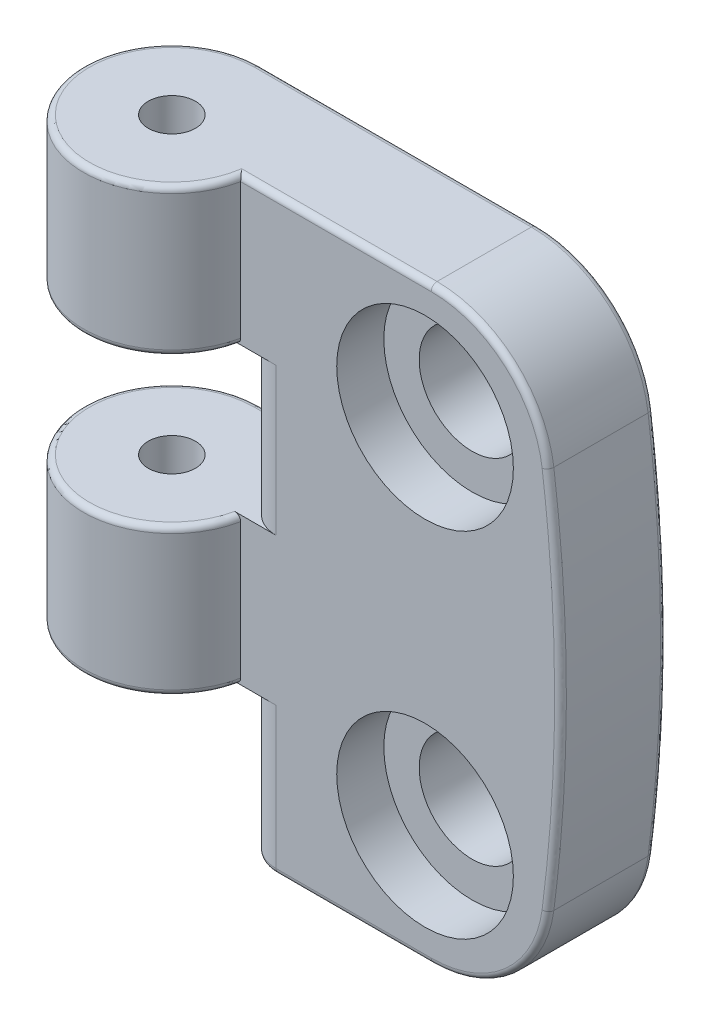
from build123d import *

# Parameters (mm, degrees)
SKETCH1_W                                           = 42
SKETCH1_H                                           = 50
BOSS_EXTRUDE1_DEPTH                                 = 15
SKETCH2_OUTSIDE_W                                   = 57.4
SKETCH2_OUTSIDE_H                                   = 30.4
SKETCH2_OUTSIDE_R                                   = 2
CUT_EXTRUDE1_DEPTH                                  = 51
CUT_EXTRUDE2_DEPTH                                  = 15
FILLET1_R                                           = 10
CBORE_FOR_M8_HEX_SOCKET_HEAD_CAP_SCREW1_D           = 9
CBORE_FOR_M8_HEX_SOCKET_HEAD_CAP_SCREW1_DEPTH       = 15
CBORE_FOR_M8_HEX_SOCKET_HEAD_CAP_SCREW1_CBORE_D     = 15
CBORE_FOR_M8_HEX_SOCKET_HEAD_CAP_SCREW1_CBORE_DEPTH = 4
CBORE_FOR_M8_HEX_SOCKET_HEAD_CAP_SCREW1_TIP         = 2.703872786
SKETCH6_W                                           = 14.848469228
SKETCH6_H                                           = 12.5
CUT_EXTRUDE3_DEPTH                                  = 7.0000001
CUT_EXTRUDE3_DEPTH_BACK                             = 10.0000001
FILLET2_R                                           = 3
FILLET3_R                                           = 0.5


with BuildPart() as part:
    # Sketch1 → Boss-Extrude1 (new body)
    with BuildSketch(Plane.XY):
        with Locations((21, 25)):
            Rectangle(SKETCH1_W, SKETCH1_H)
    extrude(amount=BOSS_EXTRUDE1_DEPTH)

    # Sketch2 outside → Cut-Extrude1 (cut, through all)
    with BuildSketch(Plane.XZ):
        with Locations((21, 7.5)):
            Rectangle(SKETCH2_OUTSIDE_W, SKETCH2_OUTSIDE_H)
        with BuildLine():
            Line((42, 0), (7.5, 0))
            ThreePointArc((7.5, 0), (1.690524981, 12.24341649), (14.848469228, 9))
            Line((14.848469228, 9), (42, 9))
            Line((42, 9), (42, 0))
        make_face(mode=Mode.SUBTRACT)
        with Locations((7.5, 7.5)):
            Circle(SKETCH2_OUTSIDE_R)
    extrude(amount=-CUT_EXTRUDE1_DEPTH, mode=Mode.SUBTRACT)

    # Sketch3 → Cut-Extrude2 (cut)
    with BuildSketch(Plane.XY.offset(9)):
        with BuildLine():
            Line((39.497510003, 50), (57.034840996, 50))
            Line((57.034840996, 50), (57.034840996, 0))
            Line((57.034840996, 0), (39.497510003, 0))
            add(Edge.make_bspline(
                [(39.497510003, 50), (44.502489997, 25), (39.497510003, 0)],
                knots=[0, 0, 0, 1, 1, 1], degree=2))
        make_face()
    extrude(amount=-CUT_EXTRUDE2_DEPTH, mode=Mode.SUBTRACT)

    # Fillet1
    fillet1_edges = [part.edges().sort_by_distance(p)[0] for p in [
        (39.497510003, 50, 4.5),
        (39.497510003, 0, 4.5),
    ]]
    fillet(fillet1_edges, radius=FILLET1_R)

    # CBORE for M8 Hex Socket Head Cap Screw1
    with Locations(Plane.XY.offset(9)):
        with Locations((30.498486782, 10), (30.498469228, 40)):
            CounterBoreHole(CBORE_FOR_M8_HEX_SOCKET_HEAD_CAP_SCREW1_D / 2, CBORE_FOR_M8_HEX_SOCKET_HEAD_CAP_SCREW1_CBORE_D / 2, CBORE_FOR_M8_HEX_SOCKET_HEAD_CAP_SCREW1_CBORE_DEPTH, depth=CBORE_FOR_M8_HEX_SOCKET_HEAD_CAP_SCREW1_DEPTH)
            with Locations((0, 0, -(CBORE_FOR_M8_HEX_SOCKET_HEAD_CAP_SCREW1_DEPTH + CBORE_FOR_M8_HEX_SOCKET_HEAD_CAP_SCREW1_TIP / 2))):  # 118° drill point
                Cone(0, CBORE_FOR_M8_HEX_SOCKET_HEAD_CAP_SCREW1_D / 2, CBORE_FOR_M8_HEX_SOCKET_HEAD_CAP_SCREW1_TIP, mode=Mode.SUBTRACT)

    # Sketch6 → Cut-Extrude3 (cut, two sides)
    with BuildSketch(Plane.XY.offset(9)) as cut_extrude3_sk:
        with Locations((7.424234614, 6.25)):
            Rectangle(SKETCH6_W, SKETCH6_H)
        with Locations((7.424234614, 31.25)):
            Rectangle(SKETCH6_W, SKETCH6_H)
    extrude(amount=CUT_EXTRUDE3_DEPTH, mode=Mode.SUBTRACT)
    extrude(cut_extrude3_sk.sketch, amount=-CUT_EXTRUDE3_DEPTH_BACK, mode=Mode.SUBTRACT)

    # Fillet2
    fillet2_edges = [part.edges().sort_by_distance(p)[0] for p in [
        (14.848469228, 31.25, 9),
        (14.848469228, 6.25, 9),
        (14.848469228, 6.25, 0),
        (14.848469228, 31.25, 0),
    ]]
    fillet(fillet2_edges, radius=FILLET2_R)

    # Fillet3
    fillet3_edges = [part.edges().sort_by_distance(p)[0] for p in [
        (1.690524981, 12.5, 12.24341649),
        (11.174234614, 12.5, 0),
        (1.690524981, 37.5, 12.24341649),
        (11.174234614, 37.5, 0),
        (1.690524981, 25, 12.24341649),
        (11.174234614, 25, 0),
        (24.434754493, 0, 0),
        (14.848469228, 0, 4.5),
        (15.727148885, 0, 8.121320344),
        (15.727148885, 0, 0.878679656),
        (1.690524981, 50, 12.24341649),
        (42, 25, 0),
        (42, 25, 9),
        (22.934754493, 50, 9),
        (24.434754493, 0, 9),
        (37.618828061, 2.485401574, 9),
        (37.618828061, 47.514598426, 9),
        (19.260519879, 50, 0),
        (37.618828061, 2.485401574, 0),
        (37.618828061, 47.514598426, 0),
    ]]
    fillet(fillet3_edges, radius=FILLET3_R)


solid = part.part
